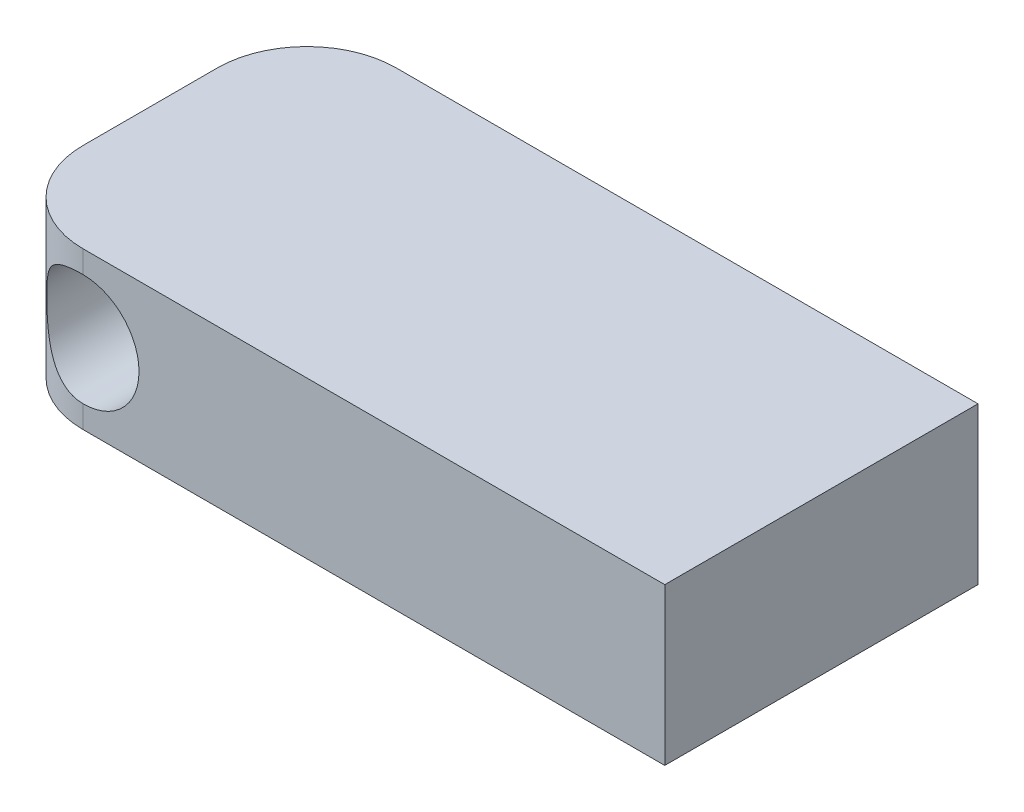
from build123d import *

# Parameters (mm, degrees)
BOSS_EXTRUDE1_DEPTH = 7
SKETCH3_R           = 2.5
CUT_EXTRUDE1_DEPTH  = 14


with BuildPart() as part:
    # Sketch2 → Boss-Extrude1 (new body)
    with BuildSketch(Plane(origin=(0, 0, 0), x_dir=(1, 0, 0), z_dir=(0, 1, 0))):
        with BuildLine():
            Line((-2.748329621, 10.673719376), (23.251670379, 10.673719376))
            Line((23.251670379, 10.673719376), (23.251670379, -3.326280624))
            Line((23.251670379, -3.326280624), (-2.748329621, -3.326280624))
            ThreePointArc((-2.748329621, -3.326280624), (-5.576756746, -2.154707748), (-6.748329621, 0.673719376))
            Line((-6.748329621, 0.673719376), (-6.748329621, 6.673719376))
            ThreePointArc((-6.748329621, 6.673719376), (-5.576756746, 9.502146501), (-2.748329621, 10.673719376))
        make_face()
    extrude(amount=BOSS_EXTRUDE1_DEPTH)

    # Sketch3 → Cut-Extrude1 (cut)
    with BuildSketch(Plane.XY.offset(3.326280624)):
        with Locations((-2.748329621, 3.5)):
            Circle(SKETCH3_R)
    extrude(amount=-CUT_EXTRUDE1_DEPTH, mode=Mode.SUBTRACT)


solid = part.part
